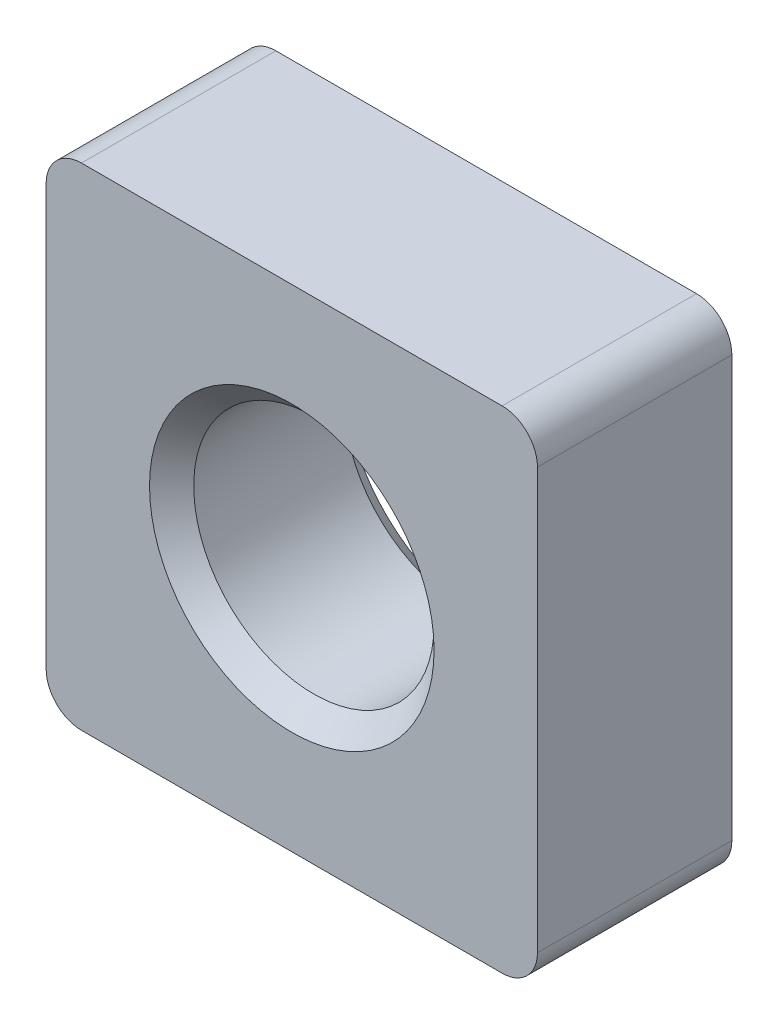
from build123d import *

# Parameters (mm, degrees)
SKETCH_1_W      = 13.9
SKETCH_1_H      = 13.9
EXTRUDE_1_DEPTH = 5.5
FILLET_1_R      = 1


with BuildPart() as part:
    # Эскиз1 → Бобышка-Вытянуть1 (new body)
    with BuildSketch(Plane.XY):
        Rectangle(SKETCH_1_W, SKETCH_1_H)
    extrude(amount=EXTRUDE_1_DEPTH)

    # Эскиз3 → Отверстие обработанное метчиком M81 (revolve, cut)
    with BuildSketch(Plane(origin=(0, 0, 5.5), x_dir=(0, -1, 0), z_dir=(1, 0, 0))):
        Polygon((0, 0), (0, 5.5), (4.025, 5.5), (3.4, 4.875), (3.4, 0.625), (4.025, 0), align=None)
    revolve(axis=Axis((0, 0, 11.85), (0, 0, -1)), mode=Mode.SUBTRACT)

    # Скругление1
    fillet_1_edges = [part.edges().sort_by_distance(p)[0] for p in [
        (6.95, -6.95, 2.75),
        (-6.95, -6.95, 2.75),
        (-6.95, 6.95, 2.75),
        (6.95, 6.95, 2.75),
    ]]
    fillet(fillet_1_edges, radius=FILLET_1_R)


solid = part.part
